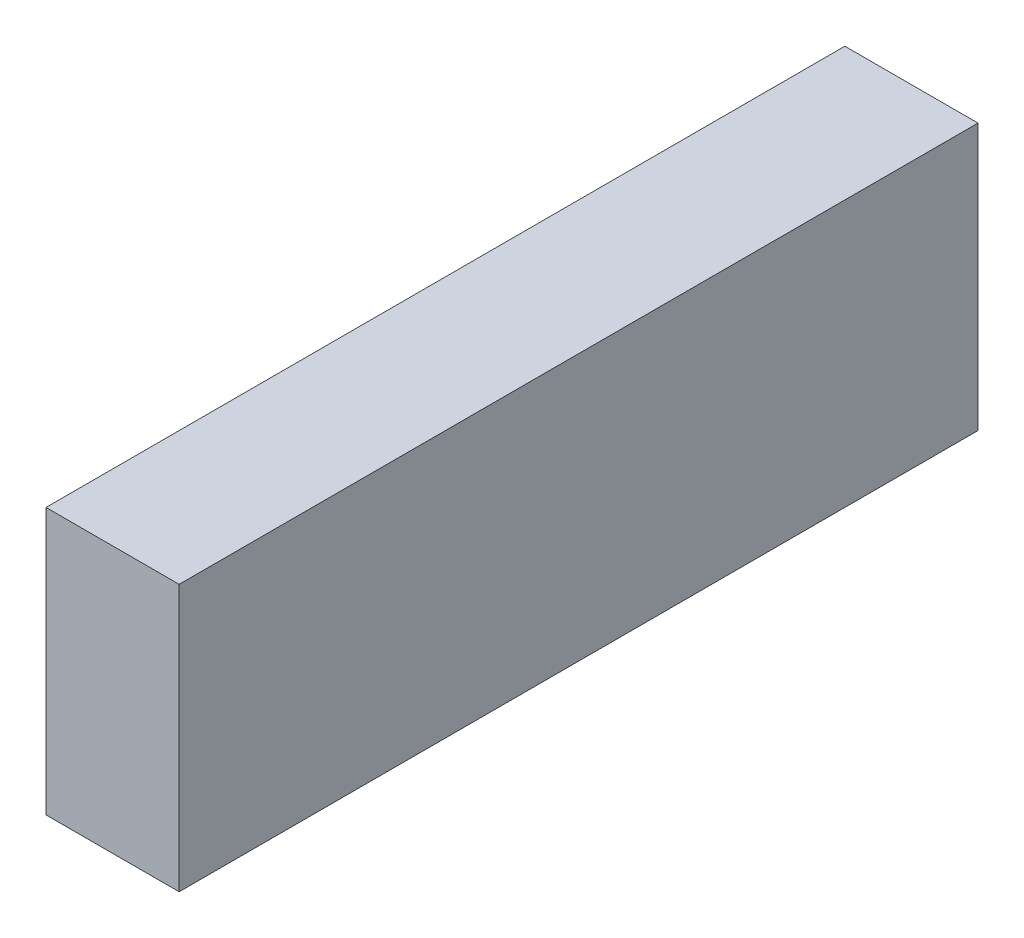
from build123d import *

# Parameters (mm, degrees)
ESQUISSE3_W        = 5
ESQUISSE3_H        = 10
BOSS_EXTRU_3_DEPTH = 15


with BuildPart() as part:
    # Esquisse3 → Boss.-Extru.3 (new body, symmetric)
    with BuildSketch(Plane.XY):
        with Locations((-77.339468619, -27.342630186)):
            Rectangle(ESQUISSE3_W, ESQUISSE3_H)
    extrude(amount=BOSS_EXTRU_3_DEPTH, both=True)


solid = part.part
